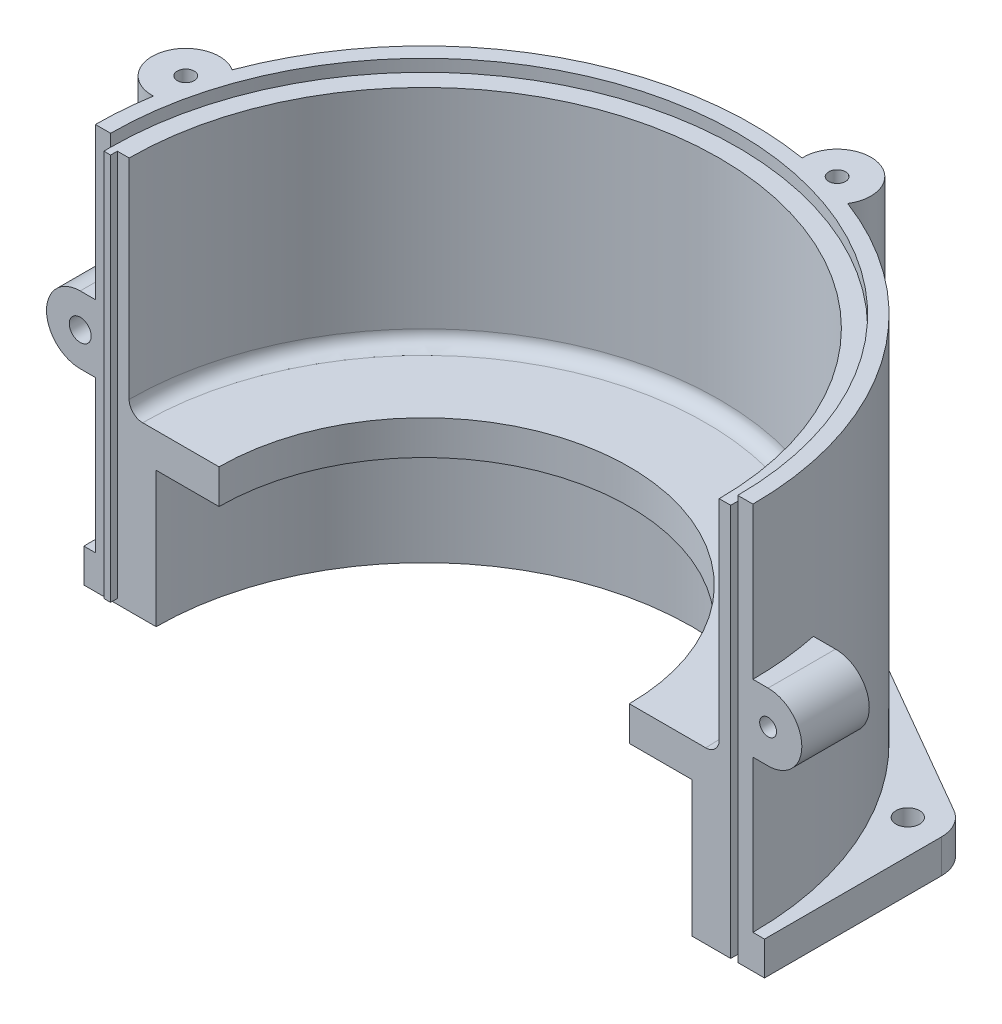
from build123d import *

# Parameters (mm, degrees)
REVOLU_O2_ANGLE             = 180
ESBO_O4_R                   = 10
RESSALTO_EXTRUS_O1_DEPTH    = 35
RESSALTO_EXTRUS_O10_DEPTH   = 10
ESBO_O8_R                   = 3.5
CORTE_EXTRUS_O2_DEPTH       = 20
PADR_OCIRCULAR1_COUNT       = 6
ESBO_O6_R                   = 2.5
CORTE_EXTRUS_O1_DEPTH       = 15
ESBO_O9_R                   = 1.25
CORTE_EXTRUS_O3_DEPTH       = 6
ESBO_O10_W                  = 2.2
ESBO_O10_H                  = 116.4
CORTE_EXTRUS_O4_DEPTH       = 3.5
ESBO_O11_W                  = 2
ESBO_O11_H                  = 114.9
RESSALTO_EXTRUS_O5_DEPTH    = 2
ESBO_O12_R                  = 3.25
RESSALTO_EXTRUS_O6_DEPTH    = 20
ESBO_O13_R                  = 2.5
RESSALTO_EXTRUS_O7_DEPTH    = 20
CORTE_EXTRUS_O6_START       = 10
ESBO_O16_R                  = 93
CORTE_EXTRUS_O6_DEPTH       = 10
CORTE_EXTRUS_O10_DEPTH      = 178.974499578
CORTE_EXTRUS_O10_DEPTH_BACK = 178.974499578
ESBO_O25_R                  = 60.842408243


with BuildPart() as part:
    # Esboço3 → Revolução2 (revolve)
    with BuildSketch(Plane.XY):
        with BuildLine():
            Line((97.5, 79.8), (97.5, 11.304491341))
            Line((97.5, 11.304491341), (97.5, 0))
            Line((97.5, 0), (97.5, -40.2))
            Line((97.5, -40.2), (79.5, -40.2))
            Line((79.5, -40.2), (79.5, 0))
            Line((79.5, 0), (60.342408243, 0))
            Line((60.342408243, 0), (60.342408243, 2.95))
            Line((60.342408243, 2.95), (52, 2.95))
            Line((52, 2.95), (44, 10.95))
            Line((44, 10.95), (31, 10.95))
            Line((31, 10.95), (31, 13.7))
            Line((31, 13.7), (22.6, 13.7))
            Line((22.6, 13.7), (22.6, 17))
            Line((22.6, 17), (19.3, 17))
            Line((19.3, 17), (19.3, 17.7))
            Line((19.3, 17.7), (15.3, 17.7))
            Line((15.3, 17.7), (15.3, 21.05))
            Line((15.3, 21.05), (19.3, 21.05))
            Line((19.3, 21.05), (19.3, 21.2))
            Line((19.3, 21.2), (27.626549127, 25.96))
            Line((27.626549127, 25.96), (31.3, 25.96))
            Line((31.3, 25.96), (31.3, 43.96))
            Line((31.3, 43.96), (32.3, 44.96))
            Line((32.3, 44.96), (38.8, 44.96))
            Line((38.8, 44.96), (38.8, 26.9))
            Line((38.8, 26.9), (55.5, 10.2))
            Line((55.5, 10.2), (83.5, 10.2))
            ThreePointArc((83.5, 10.2), (86.328427125, 11.371572875), (87.5, 14.2))
            Line((87.5, 14.2), (87.5, 76.2))
            Line((87.5, 76.2), (93, 76.2))
            Line((93, 76.2), (93, 79.8))
            Line((93, 79.8), (97.5, 79.8))
        make_face()
    revolve(axis=Axis((0, -3.322055656, 0), (0, 1, 0)), revolution_arc=REVOLU_O2_ANGLE)

    # Esboço4 → Ressalto-extrusão1 (add)
    with BuildSketch(Plane(origin=(0, 79.8, 0), x_dir=(1, 0, 0), z_dir=(0, 1, 0))):
        with Locations((25.881656302, 96.591656302)):
            Circle(ESBO_O4_R)
        with Locations((-96.591656302, 25.881656302)):
            Circle(ESBO_O4_R)
    extrude(amount=-RESSALTO_EXTRUS_O1_DEPTH)

    # Esboço23 → Ressalto-extrusão10 (add)
    with BuildSketch(Plane.XZ.offset(40.2)):
        with BuildLine():
            Line((95.932667397, -61.160254038), (5, -113.660254038))
            ThreePointArc((5, -113.660254038), (0, -115), (-5, -113.660254038))
            Line((-5, -113.660254038), (-95.932667397, -61.160254038))
            ThreePointArc((-95.932667397, -61.160254038), (-99.592921435, -57.5), (-100.932667397, -52.5))
            Line((-100.932667397, -52.5), (-100.932667397, 0))
            Line((-100.932667397, 0), (-96.380584002, 0))
            ThreePointArc((-96.380584002, 0), (0, -96.380584002), (96.380584002, 0))
            Line((96.380584002, 0), (100.932667397, 0))
            Line((100.932667397, 0), (100.932667397, -52.5))
            ThreePointArc((100.932667397, -52.5), (99.592921435, -57.5), (95.932667397, -61.160254038))
        make_face()
    extrude(amount=-RESSALTO_EXTRUS_O10_DEPTH)

    # Esboço8 → Corte-extrusão2 (cut)
    with BuildSketch(Plane.XZ.offset(40.2)):
        with Locations((0, -105)):
            Circle(ESBO_O8_R)
    corte_extrus_o2 = extrude(amount=-CORTE_EXTRUS_O2_DEPTH, mode=Mode.SUBTRACT)

    # PadrãoCircular1: Corte-extrusão2 ×6 about axis
    padr_ocircular1_axis = Axis((0, 0, 0), (0, 1, 0))
    for i in range(1, PADR_OCIRCULAR1_COUNT):
        add(corte_extrus_o2.rotate(padr_ocircular1_axis, i * 360 / PADR_OCIRCULAR1_COUNT), mode=Mode.SUBTRACT)

    # Esboço6 → Corte-extrusão1 (cut)
    with BuildSketch(Plane(origin=(0, 79.8, 0), x_dir=(1, 0, 0), z_dir=(0, 1, 0))):
        with Locations((25.881656302, 96.591656302)):
            Circle(ESBO_O6_R)
        with Locations((-96.591656302, 25.881656302)):
            Circle(ESBO_O6_R)
    extrude(amount=-CORTE_EXTRUS_O1_DEPTH, mode=Mode.SUBTRACT)

    # Esboço9 → Corte-extrusão3 (cut)
    with BuildSketch(Plane.XZ.offset(-13.7)):
        with Locations((18.738329701, -18.738329701)):
            Circle(ESBO_O9_R)
        with Locations((-18.738329701, -18.738329701)):
            Circle(ESBO_O9_R)
        with Locations((-18.738329701, 18.738329701)):
            Circle(ESBO_O9_R)
        with Locations((18.738329701, 18.738329701)):
            Circle(ESBO_O9_R)
    extrude(amount=-CORTE_EXTRUS_O3_DEPTH, mode=Mode.SUBTRACT)

    # Esboço10 → Corte-extrusão4 (cut)
    with BuildSketch(Plane.XY):
        with Locations((92, 18)):
            Rectangle(ESBO_O10_W, ESBO_O10_H)
    extrude(amount=-CORTE_EXTRUS_O4_DEPTH, mode=Mode.SUBTRACT)

    # Esboço11 → Ressalto-extrusão5 (add)
    with BuildSketch(Plane.XY):
        with Locations((-92, 18.75)):
            Rectangle(ESBO_O11_W, ESBO_O11_H)
    extrude(amount=RESSALTO_EXTRUS_O5_DEPTH)

    # Esboço12 → Ressalto-extrusão6 (add)
    with BuildSketch(Plane.XY):
        with BuildLine():
            Line((-102, 34.8), (-87.5, 34.8))
            Line((-87.5, 34.8), (-87.5, 14.8))
            Line((-87.5, 14.8), (-102, 14.8))
            ThreePointArc((-102, 14.8), (-112, 24.8), (-102, 34.8))
        make_face()
        with Locations((-102, 24.8)):
            Circle(ESBO_O12_R, mode=Mode.SUBTRACT)
    extrude(amount=-RESSALTO_EXTRUS_O6_DEPTH)

    # Esboço13 → Ressalto-extrusão7 (add)
    with BuildSketch(Plane.XY):
        with BuildLine():
            Line((102, 34.8), (93.1, 34.8))
            Line((93.1, 34.8), (93.1, 14.8))
            Line((93.1, 14.8), (102, 14.8))
            ThreePointArc((102, 14.8), (112, 24.8), (102, 34.8))
        make_face()
        with Locations((102, 24.8)):
            Circle(ESBO_O13_R, mode=Mode.SUBTRACT)
    extrude(amount=-RESSALTO_EXTRUS_O7_DEPTH)

    # Esboço16 → Corte-extrusão6 (cut)
    with BuildSketch(Plane(origin=(0, 76.2, 0), x_dir=(1, 0, 0), z_dir=(0, 1, 0)).offset(CORTE_EXTRUS_O6_START)):
        Circle(ESBO_O16_R)
    extrude(amount=-CORTE_EXTRUS_O6_DEPTH, mode=Mode.SUBTRACT)

    # Esboço25 → Corte-extrusão10 (cut, two sides: drawn at the far end of the back side and taken through both)
    with BuildSketch(Plane.XZ.offset(-2.95).offset(-CORTE_EXTRUS_O10_DEPTH_BACK)):
        Circle(ESBO_O25_R)
    extrude(amount=CORTE_EXTRUS_O10_DEPTH + CORTE_EXTRUS_O10_DEPTH_BACK, mode=Mode.SUBTRACT)


solid = part.part
